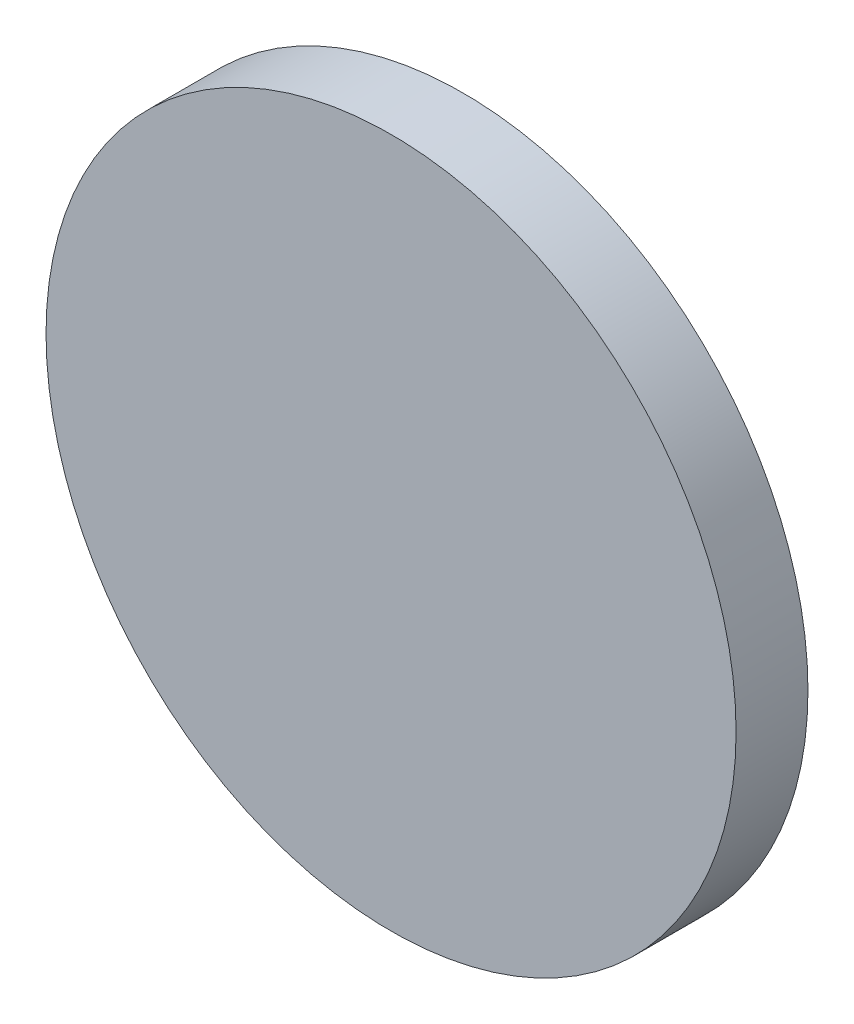
from build123d import *

# Parameters (mm, degrees)
SKETCH1_R           = 240
BOSS_EXTRUDE1_DEPTH = 50


with BuildPart() as part:
    # Sketch1 → Boss-Extrude1 (new body)
    with BuildSketch(Plane.XY):
        Circle(SKETCH1_R)
    extrude(amount=BOSS_EXTRUDE1_DEPTH)


solid = part.part
